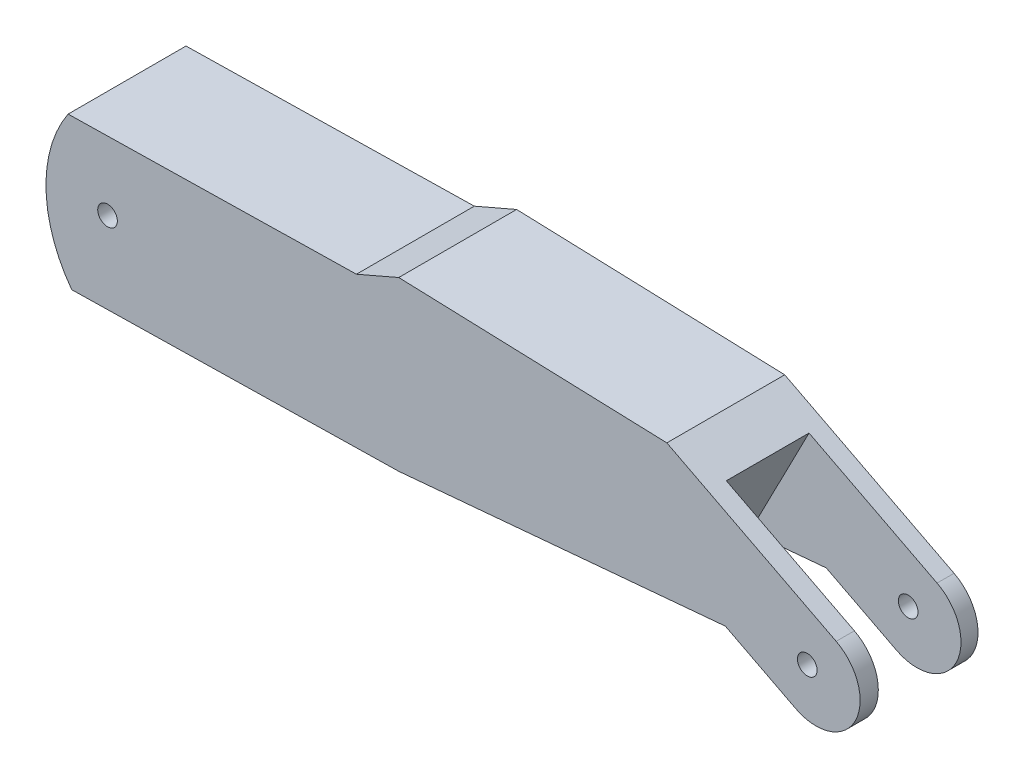
from build123d import *

# Parameters (mm, degrees)
BOSS_EXTRUDE1_DEPTH = 60
SKETCH6_W           = 104.365742104
SKETCH6_H           = 42.078428343
CUT_EXTRUDE1_DEPTH  = 60
SKETCH7_R           = 5
CUT_EXTRUDE2_DEPTH  = 80
SKETCH8_R           = 5
CUT_EXTRUDE3_DEPTH  = 80


with BuildPart() as part:
    # Sketch1 → Boss-Extrude1 (new body)
    with BuildSketch(Plane.XY):
        with BuildLine():
            Line((-221.321453318, 37.052081842), (-74.563130632, 39.85043969))
            Line((-74.563130632, 39.85043969), (-53.022046647, 49.170731686))
            Line((-53.022046647, 49.170731686), (83.431852104, 44.510585688))
            Line((83.431852104, 44.510585688), (169.619936548, 0.125236974))
            ThreePointArc((169.619936548, 0.125236974), (179.310534794, -30.143946614), (149.041351206, -39.83454486))
            Line((149.041351206, -39.83454486), (113.217328202, -21.385802628))
            Line((113.217328202, -21.385802628), (-53.022046647, -36.262839488))
            Line((-53.022046647, -36.262839488), (-219.455881419, -39.436365998))
            ThreePointArc((-219.455881419, -39.436365998), (-232.557507777, -1.488943064), (-221.321453318, 37.052081842))
        make_face()
    extrude(amount=BOSS_EXTRUDE1_DEPTH)

    # Sketch6 → Cut-Extrude1 (cut)
    with BuildSketch(Plane(origin=(35.60593299, 69.14009348, 0), x_dir=(0.889035749, -0.457837785, 0), z_dir=(0.457837785, 0.889035749, 0))):
        with Locations((129.620714118, -29.693602711)):
            Rectangle(SKETCH6_W, SKETCH6_H)
    extrude(amount=-CUT_EXTRUDE1_DEPTH, mode=Mode.SUBTRACT)

    # Sketch7 → Cut-Extrude2 (cut)
    with BuildSketch(Plane.XY.offset(60)):
        with Locations((-201.23397976, 2.428743615)):
            Circle(SKETCH7_R)
    extrude(amount=-CUT_EXTRUDE2_DEPTH, mode=Mode.SUBTRACT)

    # Sketch8 → Cut-Extrude3 (cut)
    with BuildSketch(Plane.XY.offset(60)):
        with Locations((154.912488727, -17.513734237)):
            Circle(SKETCH8_R)
    extrude(amount=-CUT_EXTRUDE3_DEPTH, mode=Mode.SUBTRACT)


solid = part.part
